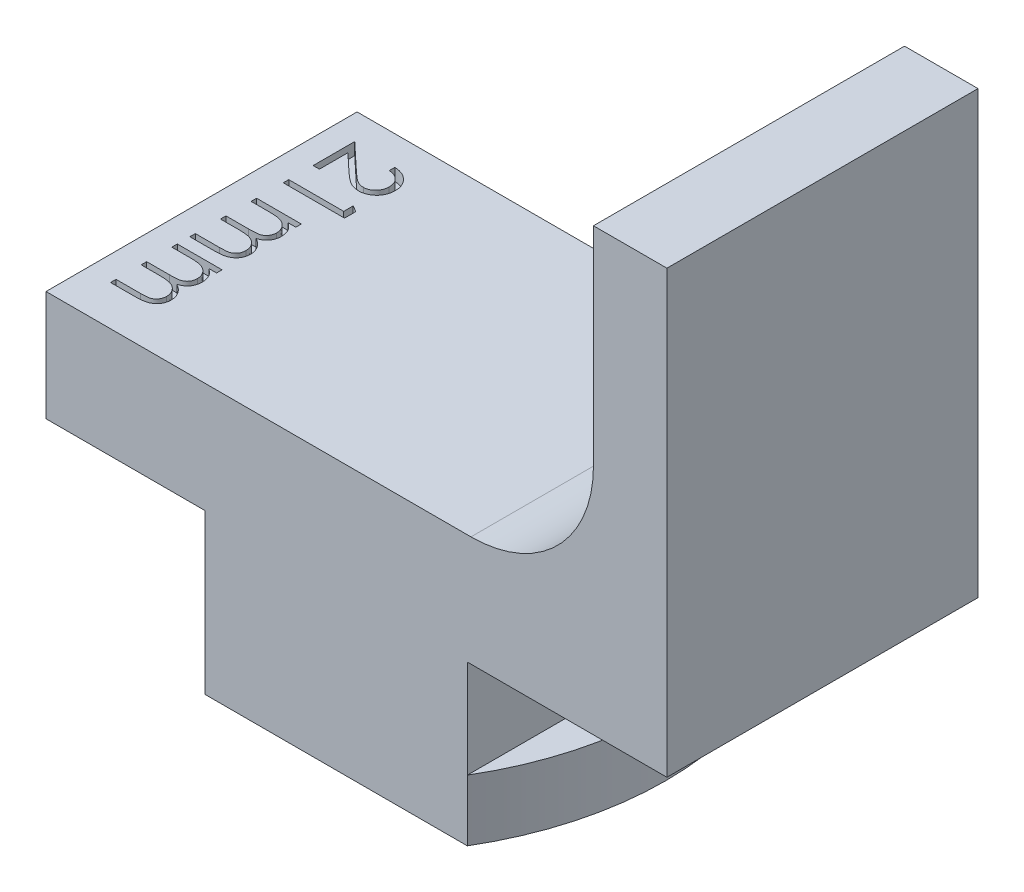
from build123d import *

# Parameters (mm, degrees)
BOSS_EXTRUDE1_DEPTH = 12.7
FILLET1_R           = 5
SKETCH2_OUTSIDE_W   = 34.844
SKETCH2_OUTSIDE_H   = 22.194
CUT_EXTRUDE1_DEPTH  = 10
CUT_EXTRUDE2_DEPTH  = 0.5


with BuildPart() as part:
    # Sketch1 → Boss-Extrude1 (new body)
    with BuildSketch(Plane.XY):
        Polygon((0, 0), (0, -4), (-1.75, -4), (-1.75, -6.5), (12.45, -6.5), (12.45, -4), (10.7, -4), (10.7, 0), (18.85, 0), (18.85, 18), (15.85, 18), (15.85, 4.5), (-6.5, 4.5), (-6.5, 0), align=None)
    extrude(amount=BOSS_EXTRUDE1_DEPTH)

    # Fillet1
    fillet1_edges = [part.edges().sort_by_distance(p)[0] for p in [
        (15.85, 4.5, 6.35),
    ]]
    fillet(fillet1_edges, radius=FILLET1_R)

    # Sketch2 outside → Cut-Extrude1 (cut)
    with BuildSketch(Plane(origin=(0, -4, 0), x_dir=(1, 0, 0), z_dir=(0, 1, 0))):
        with Locations((6.175, -6.35)):
            Rectangle(SKETCH2_OUTSIDE_W, SKETCH2_OUTSIDE_H)
        with BuildLine():
            Line((0, -12.7), (10.7, -12.7))
            ThreePointArc((10.7, -12.7), (12.45, -6.35), (10.7, 0))
            Line((10.7, 0), (0, 0))
            ThreePointArc((0, 0), (-1.75, -6.35), (0, -12.7))
        make_face(mode=Mode.SUBTRACT)
    extrude(amount=-CUT_EXTRUDE1_DEPTH, mode=Mode.SUBTRACT)

    # Sketch3 → Cut-Extrude2 (cut)
    with BuildSketch(Plane(origin=(0, 4.5, 0), x_dir=(1, 0, 0), z_dir=(0, 1, 0))):
        with BuildLine():
            Line((-3.769230769, -1.416666667), (-3.769230769, -1.192307692))
            add(Edge.make_bspline(
                [(-3.769230769, -1.192307692), (-3.739465703, -1.193769696), (-3.681007904, -1.196641031), (-3.595778619, -1.210093331), (-3.514303391, -1.229324068), (-3.437280723, -1.25657851), (-3.363790512, -1.290235363), (-3.294808625, -1.331441091), (-3.229650424, -1.379317255), (-3.169549571, -1.433776024), (-3.114609876, -1.492868808), (-3.06666458, -1.556241548), (-3.026618971, -1.623242893), (-2.992959714, -1.693291702), (-2.967725032, -1.76719811), (-2.948993088, -1.844255655), (-2.93772487, -1.924812628), (-2.936513511, -1.979698296), (-2.935897436, -2.007612179)],
                knots=[0, 0, 0, 0, 8.9345e-05, 0.000175471, 0.000258432, 0.000340159, 0.000420153, 0.000500544, 0.000580775, 0.000662333, 0.000743489, 0.000822516, 0.000900244, 0.000977304, 0.001055226, 0.001134057, 0.001214939, 0.001298647, 0.001298647, 0.001298647, 0.001298647], degree=3))
            add(Edge.make_bspline(
                [(-2.935897436, -2.007612179), (-2.936539191, -2.03502509), (-2.937800215, -2.088890479), (-2.948629522, -2.167506203), (-2.965590659, -2.242347128), (-2.989387385, -2.313266961), (-3.021376262, -2.379699864), (-3.059803075, -2.442144896), (-3.104245812, -2.501345475), (-3.156569964, -2.554636035), (-3.21242881, -2.603570377), (-3.272063027, -2.645786274), (-3.333655374, -2.681938533), (-3.397675518, -2.712072591), (-3.464726252, -2.734255547), (-3.533831397, -2.751097124), (-3.605706262, -2.760616705), (-3.654353802, -2.762077722), (-3.679086538, -2.762820513)],
                knots=[0, 0, 0, 0, 8.2206e-05, 0.000161532, 0.000237582, 0.000312174, 0.000385423, 0.000458258, 0.000531878, 0.000606964, 0.000681872, 0.000754411, 0.000825787, 0.000895917, 0.000966233, 0.001037292, 0.001109039, 0.001183241, 0.001183241, 0.001183241, 0.001183241], degree=3))
            add(Edge.make_bspline(
                [(-3.679086538, -2.762820513), (-3.71390642, -2.761611039), (-3.782935144, -2.759213317), (-3.884374332, -2.738703048), (-3.982655346, -2.706669826), (-4.061753419, -2.668100285), (-4.125491628, -2.629191397), (-4.177969275, -2.594128891), (-4.234473181, -2.553082598), (-4.294814136, -2.505455099), (-4.359464783, -2.452231619), (-4.428386065, -2.392930074), (-4.500865901, -2.327127586), (-4.550369902, -2.280942943), (-4.576021635, -2.257011218)],
                knots=[0, 0, 0, 0, 0.00010437, 0.000206908, 0.000309214, 0.000413814, 0.000469985, 0.000533183, 0.000603103, 0.000679442, 0.000763763, 0.000854314, 0.000952177, 0.001057422, 0.001057422, 0.001057422, 0.001057422], degree=3))
            Line((-4.576021635, -2.257011218), (-5.243589744, -1.631510417))
            Line((-5.243589744, -1.631510417), (-5.243589744, -2.794871795))
            Line((-5.243589744, -2.794871795), (-5.5, -2.794871795))
            Line((-5.5, -2.794871795), (-5.5, -1.096153846))
            Line((-5.5, -1.096153846), (-4.465344551, -2.065705128))
            add(Edge.make_bspline(
                [(-4.465344551, -2.065705128), (-4.440704248, -2.089312433), (-4.393375267, -2.134657234), (-4.324255471, -2.198765658), (-4.260207374, -2.256437951), (-4.200947164, -2.307712368), (-4.146810791, -2.352631099), (-4.097374002, -2.391050425), (-4.053061049, -2.42314015), (-4.001004044, -2.457148572), (-3.937370093, -2.489577858), (-3.85999724, -2.518079883), (-3.780171816, -2.535334621), (-3.726244495, -2.53741506), (-3.69911859, -2.538461538)],
                knots=[0, 0, 0, 0, 0.000102371, 0.000196633, 0.000282807, 0.00036092, 0.00043171, 0.000493817, 0.000548716, 0.000595807, 0.000680247, 0.000762311, 0.000842655, 0.000923972, 0.000923972, 0.000923972, 0.000923972], degree=3))
            add(Edge.make_bspline(
                [(-3.69911859, -2.538461538), (-3.682058563, -2.538012101), (-3.648436526, -2.537126347), (-3.599173745, -2.529161064), (-3.551469794, -2.517458483), (-3.5059145, -2.49942119), (-3.461611877, -2.477750046), (-3.419908864, -2.450063563), (-3.379383905, -2.418425182), (-3.341426566, -2.381726212), (-3.30665175, -2.341437563), (-3.275849492, -2.298868859), (-3.250107098, -2.253833431), (-3.229004646, -2.206518962), (-3.21245079, -2.157057938), (-3.200980379, -2.105354542), (-3.193778604, -2.051551675), (-3.192804196, -2.014813464), (-3.192307692, -1.99609375)],
                knots=[0, 0, 0, 0, 5.1143e-05, 0.000100793, 0.000149379, 0.000198206, 0.000247478, 0.000297068, 0.000348064, 0.000401546, 0.00045516, 0.000507556, 0.000558926, 0.000610487, 0.000662748, 0.000715112, 0.000769155, 0.0008253, 0.0008253, 0.0008253, 0.0008253], degree=3))
            add(Edge.make_bspline(
                [(-3.192307692, -1.99609375), (-3.192818275, -1.976543068), (-3.193820976, -1.938148758), (-3.200839356, -1.881779251), (-3.212935551, -1.827999215), (-3.229519178, -1.776699782), (-3.250398096, -1.727831527), (-3.276905454, -1.681836316), (-3.308006308, -1.638294229), (-3.343459583, -1.597285236), (-3.383118274, -1.559604405), (-3.426783108, -1.525801638), (-3.474738119, -1.496971452), (-3.525900148, -1.471414789), (-3.581629531, -1.451860159), (-3.640575816, -1.43514505), (-3.703576488, -1.423002759), (-3.746982525, -1.418813776), (-3.769230769, -1.416666667)],
                knots=[0, 0, 0, 0, 5.8647e-05, 0.000115173, 0.000170091, 0.000223779, 0.000276715, 0.000329204, 0.000382705, 0.000437025, 0.000491578, 0.000546571, 0.000602313, 0.000659202, 0.000717819, 0.000779181, 0.000842925, 0.000909953, 0.000909953, 0.000909953, 0.000909953], degree=3))
        make_face()
        Polygon((-3, -3.550580929), (-3, -4.012820513), (-5.5, -4.012820513), (-5.5, -3.788461538), (-3.256410256, -3.788461538), (-3.256410256, -3.403846154), align=None)
        with BuildLine():
            Line((-3.673076923, -5.102564103), (-3.673076923, -5.326923077))
            Line((-3.673076923, -5.326923077), (-3.990584936, -5.326923077))
            add(Edge.make_bspline(
                [(-3.990584936, -5.326923077), (-3.962849174, -5.34716972), (-3.90979484, -5.385898498), (-3.839103141, -5.448797063), (-3.780096742, -5.512713891), (-3.748715772, -5.558420094), (-3.733673878, -5.580328526)],
                knots=[0, 0, 0, 0, 0.000102966, 0.000196958, 0.000283467, 0.000363109, 0.000363109, 0.000363109, 0.000363109], degree=3))
            add(Edge.make_bspline(
                [(-3.733673878, -5.580328526), (-3.719384332, -5.610231856), (-3.691054893, -5.66951607), (-3.662316637, -5.763386945), (-3.64465585, -5.85944028), (-3.642240584, -5.92430329), (-3.641025641, -5.95693109)],
                knots=[0, 0, 0, 0, 9.9308e-05, 0.000196881, 0.000293544, 0.000391385, 0.000391385, 0.000391385, 0.000391385], degree=3))
            add(Edge.make_bspline(
                [(-3.641025641, -5.95693109), (-3.641774259, -5.978996712), (-3.643255733, -6.022663392), (-3.652841119, -6.087378046), (-3.669609496, -6.150240939), (-3.692373764, -6.210844306), (-3.720823163, -6.267595926), (-3.753536683, -6.319722966), (-3.790488617, -6.366585325), (-3.833109774, -6.408107089), (-3.882637794, -6.445441216), (-3.940397397, -6.479783522), (-4.007688759, -6.511515734), (-4.056521976, -6.529102395), (-4.082231571, -6.538361378)],
                knots=[0, 0, 0, 0, 6.6199e-05, 0.000131004, 0.000195748, 0.000261045, 0.000324875, 0.00038587, 0.00044539, 0.00050347, 0.000563868, 0.000631031, 0.000704732, 0.000786676, 0.000786676, 0.000786676, 0.000786676], degree=3))
            add(Edge.make_bspline(
                [(-4.082231571, -6.538361378), (-4.064571271, -6.548155129), (-4.029818282, -6.567427856), (-3.980633806, -6.599789024), (-3.934628967, -6.633694597), (-3.891767192, -6.669433505), (-3.852260399, -6.706879695), (-3.815977042, -6.746209064), (-3.782764696, -6.787198937), (-3.743952279, -6.844189786), (-3.702887596, -6.918231383), (-3.666820915, -7.011609342), (-3.644996157, -7.10893871), (-3.642355706, -7.17510418), (-3.641025641, -7.208433494)],
                knots=[0, 0, 0, 0, 6.0564e-05, 0.000119181, 0.000176474, 0.000231939, 0.000286492, 0.000339652, 0.000392367, 0.000444597, 0.000546357, 0.000645594, 0.000744022, 0.000843928, 0.000843928, 0.000843928, 0.000843928], degree=3))
            add(Edge.make_bspline(
                [(-3.641025641, -7.208433494), (-3.642180799, -7.23906311), (-3.644441555, -7.299008243), (-3.662194036, -7.386277718), (-3.692678069, -7.467664722), (-3.734273524, -7.543005491), (-3.786544369, -7.610976786), (-3.848736396, -7.670059864), (-3.920409698, -7.719895838), (-3.987832547, -7.752452009), (-4.047357785, -7.774534341), (-4.098076565, -7.788149508), (-4.153899102, -7.800177862), (-4.214892146, -7.810164466), (-4.281271152, -7.817463431), (-4.352927492, -7.822871085), (-4.429916858, -7.826531138), (-4.483035072, -7.826789761), (-4.510416667, -7.826923077)],
                knots=[0, 0, 0, 0, 9.1843e-05, 0.000179747, 0.000265793, 0.000351646, 0.00043699, 0.000522005, 0.000607999, 0.000697811, 0.000745818, 0.000798306, 0.00085518, 0.000917093, 0.000983624, 0.00105545, 0.001132653, 0.001214791, 0.001214791, 0.001214791, 0.001214791], degree=3))
            Line((-4.510416667, -7.826923077), (-5.5, -7.826923077))
            Line((-5.5, -7.826923077), (-5.5, -7.602564103))
            Line((-5.5, -7.602564103), (-4.509415064, -7.602564103))
            add(Edge.make_bspline(
                [(-4.509415064, -7.602564103), (-4.486043226, -7.602508472), (-4.441126106, -7.602401558), (-4.37666007, -7.600477536), (-4.317896958, -7.596852311), (-4.264916893, -7.592613284), (-4.217596337, -7.586724846), (-4.176030302, -7.579120619), (-4.139891931, -7.571065101), (-4.09983021, -7.557682379), (-4.055638935, -7.536290165), (-4.007972189, -7.503709763), (-3.966512436, -7.462646464), (-3.930306263, -7.415180793), (-3.901462215, -7.361006762), (-3.880083749, -7.301550172), (-3.867445823, -7.237011557), (-3.866083249, -7.192297345), (-3.865384615, -7.169370994)],
                knots=[0, 0, 0, 0, 7.0114e-05, 0.000134748, 0.000193447, 0.000246723, 0.00029418, 0.00033642, 0.000373469, 0.000405143, 0.000462933, 0.000520167, 0.000577538, 0.000637235, 0.000698627, 0.000760882, 0.000826196, 0.000894922, 0.000894922, 0.000894922, 0.000894922], degree=3))
            add(Edge.make_bspline(
                [(-3.865384615, -7.169370994), (-3.866418184, -7.141041216), (-3.868466848, -7.084888039), (-3.888606496, -7.003053701), (-3.919724694, -6.924627707), (-3.964153253, -6.851718167), (-4.017610819, -6.784563992), (-4.081140155, -6.726776322), (-4.15302033, -6.679039661), (-4.219553274, -6.646715238), (-4.279317224, -6.626294332), (-4.331529618, -6.612810815), (-4.390873599, -6.60232268), (-4.456950377, -6.592486587), (-4.530214792, -6.586066782), (-4.610327936, -6.58023223), (-4.697530764, -6.577503042), (-4.757978398, -6.577121286), (-4.789362981, -6.576923077)],
                knots=[0, 0, 0, 0, 8.4849e-05, 0.00016818, 0.000251319, 0.00033712, 0.000423311, 0.000508035, 0.000593596, 0.0006814, 0.000729071, 0.000782881, 0.000842994, 0.000909781, 0.000983233, 0.001063551, 0.001150742, 0.001244898, 0.001244898, 0.001244898, 0.001244898], degree=3))
            Line((-4.789362981, -6.576923077), (-5.5, -6.576923077))
            Line((-5.5, -6.576923077), (-5.5, -6.352564103))
            Line((-5.5, -6.352564103), (-4.571013622, -6.352564103))
            add(Edge.make_bspline(
                [(-4.571013622, -6.352564103), (-4.544803812, -6.352509908), (-4.494378771, -6.352405644), (-4.42207291, -6.350460515), (-4.356287876, -6.34693718), (-4.29718885, -6.342386504), (-4.24461523, -6.337447467), (-4.198739476, -6.329631306), (-4.159370692, -6.321483736), (-4.115774829, -6.3090498), (-4.068483866, -6.287513236), (-4.017684108, -6.25475381), (-3.972914287, -6.214057471), (-3.934949709, -6.165705663), (-3.90383078, -6.111106833), (-3.881062877, -6.051037003), (-3.867930796, -5.985875666), (-3.866249348, -5.940965122), (-3.865384615, -5.91786859)],
                knots=[0, 0, 0, 0, 7.8627e-05, 0.000151271, 0.00021697, 0.000276236, 0.000329108, 0.000375296, 0.000415765, 0.000449679, 0.000511104, 0.000570834, 0.000630394, 0.000691713, 0.000754513, 0.000818227, 0.000883639, 0.000952896, 0.000952896, 0.000952896, 0.000952896], degree=3))
            add(Edge.make_bspline(
                [(-3.865384615, -5.91786859), (-3.866477801, -5.890714153), (-3.868656482, -5.836596325), (-3.888266677, -5.757094916), (-3.918983875, -5.680319438), (-3.961598025, -5.607494611), (-4.014383105, -5.540584666), (-4.076465083, -5.482006737), (-4.147071879, -5.432764324), (-4.212902559, -5.400091429), (-4.271171658, -5.379037283), (-4.320699289, -5.364983294), (-4.375763388, -5.353197643), (-4.436243472, -5.343207902), (-4.50226507, -5.335690764), (-4.573641592, -5.331193303), (-4.65059847, -5.327239971), (-4.703719911, -5.327031299), (-4.731270032, -5.326923077)],
                knots=[0, 0, 0, 0, 8.1352e-05, 0.000162132, 0.000244155, 0.000328761, 0.000414326, 0.000498997, 0.000583882, 0.000671677, 0.000718571, 0.000769613, 0.000825997, 0.000887416, 0.00095345, 0.001025239, 0.001101942, 0.00118458, 0.00118458, 0.00118458, 0.00118458], degree=3))
            Line((-4.731270032, -5.326923077), (-5.5, -5.326923077))
            Line((-5.5, -5.326923077), (-5.5, -5.102564103))
            Line((-5.5, -5.102564103), (-3.673076923, -5.102564103))
        make_face()
        with BuildLine():
            Line((-3.673076923, -8.33974359), (-3.673076923, -8.564102564))
            Line((-3.673076923, -8.564102564), (-3.990584936, -8.564102564))
            add(Edge.make_bspline(
                [(-3.990584936, -8.564102564), (-3.962849174, -8.584349207), (-3.90979484, -8.623077985), (-3.839103141, -8.68597655), (-3.780096742, -8.749893378), (-3.748715772, -8.795599581), (-3.733673878, -8.817508013)],
                knots=[0, 0, 0, 0, 0.000102966, 0.000196958, 0.000283467, 0.000363109, 0.000363109, 0.000363109, 0.000363109], degree=3))
            add(Edge.make_bspline(
                [(-3.733673878, -8.817508013), (-3.719384332, -8.847411343), (-3.691054893, -8.906695557), (-3.662316637, -9.000566432), (-3.64465585, -9.096619767), (-3.642240584, -9.161482777), (-3.641025641, -9.194110577)],
                knots=[0, 0, 0, 0, 9.9308e-05, 0.000196881, 0.000293544, 0.000391385, 0.000391385, 0.000391385, 0.000391385], degree=3))
            add(Edge.make_bspline(
                [(-3.641025641, -9.194110577), (-3.641774259, -9.216176199), (-3.643255733, -9.25984288), (-3.652841119, -9.324557533), (-3.669609496, -9.387420426), (-3.692373764, -9.448023794), (-3.720823163, -9.504775413), (-3.753536683, -9.556902453), (-3.790488617, -9.603764812), (-3.833109774, -9.645286576), (-3.882637794, -9.682620703), (-3.940397397, -9.716963009), (-4.007688759, -9.748695221), (-4.056521976, -9.766281882), (-4.082231571, -9.775540865)],
                knots=[0, 0, 0, 0, 6.6199e-05, 0.000131004, 0.000195748, 0.000261045, 0.000324875, 0.00038587, 0.00044539, 0.00050347, 0.000563868, 0.000631031, 0.000704732, 0.000786676, 0.000786676, 0.000786676, 0.000786676], degree=3))
            add(Edge.make_bspline(
                [(-4.082231571, -9.775540865), (-4.064571271, -9.785334616), (-4.029818282, -9.804607343), (-3.980633806, -9.836968511), (-3.934628967, -9.870874084), (-3.891767192, -9.906612993), (-3.852260399, -9.944059182), (-3.815977042, -9.983388551), (-3.782764696, -10.024378424), (-3.743952279, -10.081369273), (-3.702887596, -10.15541087), (-3.666820915, -10.24878883), (-3.644996157, -10.346118198), (-3.642355706, -10.412283667), (-3.641025641, -10.445612981)],
                knots=[0, 0, 0, 0, 6.0564e-05, 0.000119181, 0.000176474, 0.000231939, 0.000286492, 0.000339652, 0.000392367, 0.000444597, 0.000546357, 0.000645594, 0.000744022, 0.000843928, 0.000843928, 0.000843928, 0.000843928], degree=3))
            add(Edge.make_bspline(
                [(-3.641025641, -10.445612981), (-3.642180799, -10.476242597), (-3.644441555, -10.53618773), (-3.662194036, -10.623457206), (-3.692678069, -10.704844209), (-3.734273524, -10.780184978), (-3.786544369, -10.848156273), (-3.848736396, -10.907239351), (-3.920409698, -10.957075325), (-3.987832547, -10.989631496), (-4.047357785, -11.011713828), (-4.098076565, -11.025328995), (-4.153899102, -11.037357349), (-4.214892146, -11.047343953), (-4.281271152, -11.054642919), (-4.352927492, -11.060050572), (-4.429916858, -11.063710625), (-4.483035072, -11.063969248), (-4.510416667, -11.064102564)],
                knots=[0, 0, 0, 0, 9.1843e-05, 0.000179747, 0.000265793, 0.000351646, 0.00043699, 0.000522005, 0.000607999, 0.000697811, 0.000745818, 0.000798306, 0.00085518, 0.000917093, 0.000983624, 0.00105545, 0.001132653, 0.001214791, 0.001214791, 0.001214791, 0.001214791], degree=3))
            Line((-4.510416667, -11.064102564), (-5.5, -11.064102564))
            Line((-5.5, -11.064102564), (-5.5, -10.83974359))
            Line((-5.5, -10.83974359), (-4.509415064, -10.83974359))
            add(Edge.make_bspline(
                [(-4.509415064, -10.83974359), (-4.486043226, -10.839687959), (-4.441126106, -10.839581045), (-4.37666007, -10.837657023), (-4.317896958, -10.834031798), (-4.264916893, -10.829792772), (-4.217596337, -10.823904333), (-4.176030302, -10.816300107), (-4.139891931, -10.808244588), (-4.09983021, -10.794861866), (-4.055638935, -10.773469652), (-4.007972189, -10.74088925), (-3.966512436, -10.699825951), (-3.930306263, -10.65236028), (-3.901462215, -10.598186249), (-3.880083749, -10.53872966), (-3.867445823, -10.474191045), (-3.866083249, -10.429476832), (-3.865384615, -10.406550481)],
                knots=[0, 0, 0, 0, 7.0114e-05, 0.000134748, 0.000193447, 0.000246723, 0.00029418, 0.00033642, 0.000373469, 0.000405143, 0.000462933, 0.000520167, 0.000577538, 0.000637235, 0.000698627, 0.000760882, 0.000826196, 0.000894922, 0.000894922, 0.000894922, 0.000894922], degree=3))
            add(Edge.make_bspline(
                [(-3.865384615, -10.406550481), (-3.866418184, -10.378220703), (-3.868466848, -10.322067526), (-3.888606496, -10.240233188), (-3.919724694, -10.161807194), (-3.964153253, -10.088897654), (-4.017610819, -10.021743479), (-4.081140155, -9.96395581), (-4.15302033, -9.916219148), (-4.219553274, -9.883894726), (-4.279317224, -9.863473819), (-4.331529618, -9.849990302), (-4.390873599, -9.839502167), (-4.456950377, -9.829666074), (-4.530214792, -9.823246269), (-4.610327936, -9.817411717), (-4.697530764, -9.814682529), (-4.757978398, -9.814300773), (-4.789362981, -9.814102564)],
                knots=[0, 0, 0, 0, 8.4849e-05, 0.00016818, 0.000251319, 0.00033712, 0.000423311, 0.000508035, 0.000593596, 0.0006814, 0.000729071, 0.000782881, 0.000842994, 0.000909781, 0.000983233, 0.001063551, 0.001150742, 0.001244898, 0.001244898, 0.001244898, 0.001244898], degree=3))
            Line((-4.789362981, -9.814102564), (-5.5, -9.814102564))
            Line((-5.5, -9.814102564), (-5.5, -9.58974359))
            Line((-5.5, -9.58974359), (-4.571013622, -9.58974359))
            add(Edge.make_bspline(
                [(-4.571013622, -9.58974359), (-4.544803812, -9.589689396), (-4.494378771, -9.589585131), (-4.42207291, -9.587640002), (-4.356287876, -9.584116667), (-4.29718885, -9.579565992), (-4.24461523, -9.574626954), (-4.198739476, -9.566810793), (-4.159370692, -9.558663223), (-4.115774829, -9.546229287), (-4.068483866, -9.524692723), (-4.017684108, -9.491933297), (-3.972914287, -9.451236958), (-3.934949709, -9.40288515), (-3.90383078, -9.34828632), (-3.881062877, -9.28821649), (-3.867930796, -9.223055153), (-3.866249348, -9.178144609), (-3.865384615, -9.155048077)],
                knots=[0, 0, 0, 0, 7.8627e-05, 0.000151271, 0.00021697, 0.000276236, 0.000329108, 0.000375296, 0.000415765, 0.000449679, 0.000511104, 0.000570834, 0.000630394, 0.000691713, 0.000754513, 0.000818227, 0.000883639, 0.000952896, 0.000952896, 0.000952896, 0.000952896], degree=3))
            add(Edge.make_bspline(
                [(-3.865384615, -9.155048077), (-3.866477801, -9.12789364), (-3.868656482, -9.073775813), (-3.888266677, -8.994274403), (-3.918983875, -8.917498926), (-3.961598025, -8.844674098), (-4.014383105, -8.777764153), (-4.076465083, -8.719186224), (-4.147071879, -8.669943811), (-4.212902559, -8.637270916), (-4.271171658, -8.61621677), (-4.320699289, -8.602162781), (-4.375763388, -8.59037713), (-4.436243472, -8.580387389), (-4.50226507, -8.572870251), (-4.573641592, -8.56837279), (-4.65059847, -8.564419458), (-4.703719911, -8.564210786), (-4.731270032, -8.564102564)],
                knots=[0, 0, 0, 0, 8.1352e-05, 0.000162132, 0.000244155, 0.000328761, 0.000414326, 0.000498997, 0.000583882, 0.000671677, 0.000718571, 0.000769613, 0.000825997, 0.000887416, 0.00095345, 0.001025239, 0.001101942, 0.00118458, 0.00118458, 0.00118458, 0.00118458], degree=3))
            Line((-4.731270032, -8.564102564), (-5.5, -8.564102564))
            Line((-5.5, -8.564102564), (-5.5, -8.33974359))
            Line((-5.5, -8.33974359), (-3.673076923, -8.33974359))
        make_face()
    extrude(amount=-CUT_EXTRUDE2_DEPTH, mode=Mode.SUBTRACT)


solid = part.part
